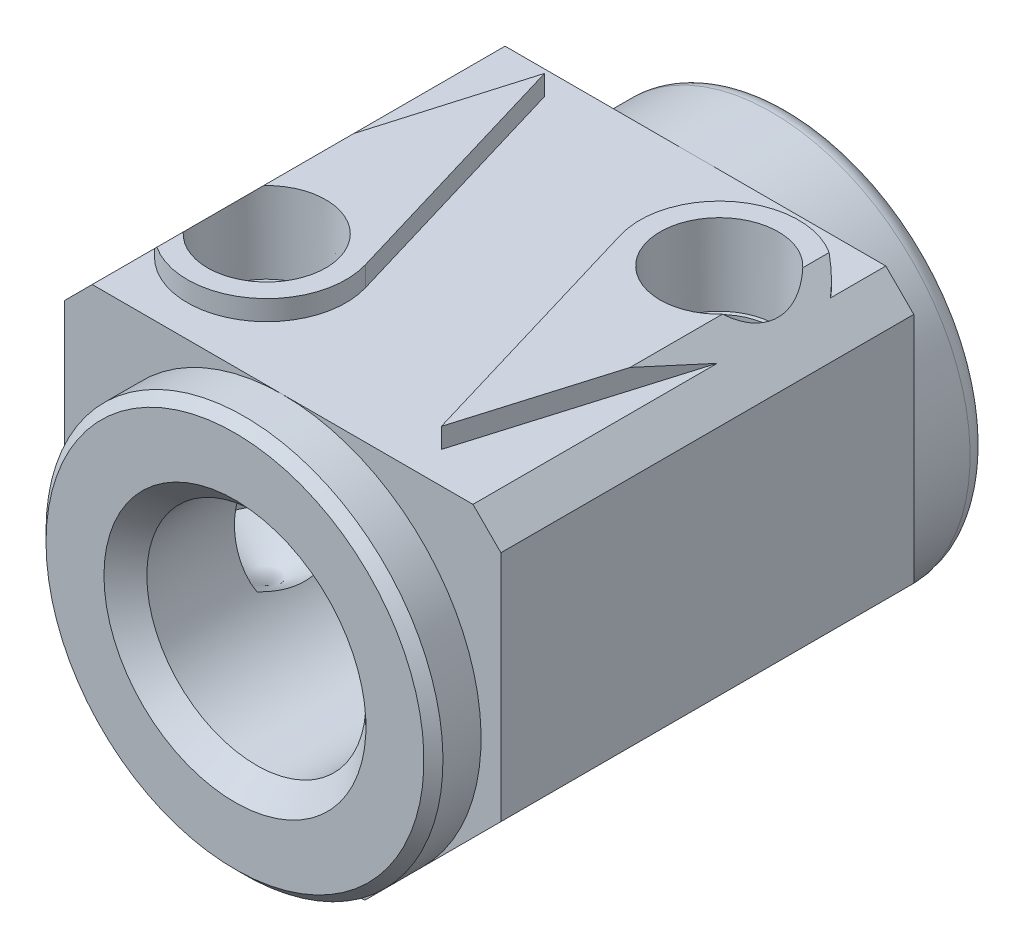
from build123d import *

# Parameters (mm, degrees)
SKETCH1_W                         = 34.925
SKETCH1_H                         = 33.3502
EXTRUDE1_DEPTH                    = 44.45
CUT_EXTRUDE1_DEPTH                = 44.45
SKETCH3_OUTSIDE_W                 = 50.051
SKETCH3_OUTSIDE_H                 = 48.476
SKETCH3_OUTSIDE_R                 = 15.875
CUT_EXTRUDE2_DEPTH                = 3.81
F_1_8_NPT_TAPPED_HOLE1_AT_2_COUNT = 2
F_1_8_NPT_TAPPED_HOLE1_AT_2_PITCH = 25.78600444
SKETCH5_OUTSIDE_W                 = 50.051
SKETCH5_OUTSIDE_H                 = 48.476
SKETCH5_OUTSIDE_R                 = 15.875
CUT_EXTRUDE3_DEPTH                = 7.62
SKETCH6_W                         = 34.925
SKETCH6_H                         = 33.02
CUT_EXTRUDE4_DEPTH                = 1.6002
CUT_EXTRUDE5_DEPTH                = 45.45
F_5_8_0_625_DIAMETER_HOLE1_D      = 15.875
F_3_4_16_TAPPED_HOLE1_D           = 17.526
F_3_4_16_TAPPED_HOLE1_DEPTH       = 25.4
F_3_4_16_TAPPED_HOLE1_TIP         = 5.265341605
SKETCH16_R                        = 10.16
CUT_EXTRUDE7_DEPTH                = 3.556
CHAMFER1_SIZE                     = 0.762
FILLET1_R                         = 1.524
CHAMFER2_SIZE                     = 1.7145
SKETCH18_R                        = 8.763
CUT_EXTRUDE9_DEPTH                = 7.62


with BuildPart() as part:
    # Sketch1 → Extrude1 (new body)
    with BuildSketch(Plane.XY):
        with Locations((17.4625, 16.6751)):
            Rectangle(SKETCH1_W, SKETCH1_H)
    extrude(amount=EXTRUDE1_DEPTH)

    # Sketch2 → Cut-Extrude1 (cut)
    with BuildSketch(Plane.XY.offset(44.45)):
        Polygon((24.038140303, 0), (34.925, 10.886859697), (38.95323648, 7.676224118), (37.650767603, -4.874839611), (-1.660111248, -5.999699096), (-2.784970733, 8.327458557), (0, 10.886859697), (10.886859697, 0), (18.528156354, -3.690776995), align=None)
    extrude(amount=-CUT_EXTRUDE1_DEPTH, mode=Mode.SUBTRACT)

    # Sketch3 outside → Cut-Extrude2 (cut)
    with BuildSketch(Plane.XY.offset(44.45)):
        with Locations((17.4625, 16.675)):
            Rectangle(SKETCH3_OUTSIDE_W, SKETCH3_OUTSIDE_H)
        with Locations((17.4625, 15.875)):
            Circle(SKETCH3_OUTSIDE_R, mode=Mode.SUBTRACT)
    extrude(amount=-CUT_EXTRUDE2_DEPTH, mode=Mode.SUBTRACT)

    # Sketch4 → 1/8 NPT Tapped Hole1 (revolve, cut)
    with BuildSketch(Plane(origin=(7.3025, 33.3502, 31.75), x_dir=(0, 0, 1), z_dir=(1, 0, 0))):
        Polygon((0, 0), (0, 24.377468714), (4.2164, 21.844), (4.2164, 6.35), (4.537409396, 6.35), (4.7275369, 0), align=None)
    f_1_8_npt_tapped_hole1 = revolve(axis=Axis((7.3025, 39.7002, 31.75), (0, -1, 0)), mode=Mode.SUBTRACT)

    # 1/8 NPT Tapped Hole1 at 2: 1/8 NPT Tapped Hole1 ×2
    with Locations(*[Vector(0.788024374, 0, -0.615644042) * (i * F_1_8_NPT_TAPPED_HOLE1_AT_2_PITCH) for i in range(1, F_1_8_NPT_TAPPED_HOLE1_AT_2_COUNT)]):
        add(f_1_8_npt_tapped_hole1, mode=Mode.SUBTRACT)

    # Sketch5 outside → Cut-Extrude3 (cut)
    with BuildSketch(Plane(origin=(0, 0, 0), x_dir=(-1, 0, 0), z_dir=(0, 0, -1))):
        with Locations((-17.4625, 16.675)):
            Rectangle(SKETCH5_OUTSIDE_W, SKETCH5_OUTSIDE_H)
        with Locations(Location((-17.4625, 15.875, 0), (0, 0, 180))):  # turned: the seam where the file's is
            Circle(SKETCH5_OUTSIDE_R, mode=Mode.SUBTRACT)
    extrude(amount=-CUT_EXTRUDE3_DEPTH, mode=Mode.SUBTRACT)

    # Sketch6 → Cut-Extrude4 (cut)
    with BuildSketch(Plane(origin=(0, 33.3502, 0), x_dir=(-1, 0, 0), z_dir=(0, 1, 0))):
        with Locations((-17.4625, 24.13)):
            Rectangle(SKETCH6_W, SKETCH6_H)
        with BuildLine():
            Line((-33.707799282, 17.689285714), (-27.6225, 38.1))
            Line((-27.6225, 38.1), (-21.537200718, 17.689285714))
            ThreePointArc((-21.537200718, 17.689285714), (-27.6225, 9.525), (-33.707799282, 17.689285714))
        make_face(mode=Mode.SUBTRACT)
        with BuildLine():
            Line((-7.3025, 9.525), (-13.387799282, 29.935714286))
            ThreePointArc((-13.387799282, 29.935714286), (-7.839432762, 38.077258744), (-0.998497845, 30.98707351))
            ThreePointArc((-0.998497845, 30.98707351), (-1.209886072, 29.96043147), (-1.587281519, 28.982550324))
            Line((-1.587281519, 28.982550324), (-7.3025, 9.525))
        make_face(mode=Mode.SUBTRACT)
    extrude(amount=-CUT_EXTRUDE4_DEPTH, mode=Mode.SUBTRACT)

    # Sketch8 → Cut-Extrude5 (cut, through all)
    with BuildSketch(Plane.XY.offset(44.45)):
        Polygon((0, 29.5148), (8.827956785, 38.342756785), (29.988545511, 34.451254489), (34.925, 29.5148), (37.769173864, 38.094844764), (-2.725767603, 41.455222953), (-4.620267788, 29.436987401), align=None)
    extrude(amount=-CUT_EXTRUDE5_DEPTH, mode=Mode.SUBTRACT)

    # 5/8 (0.625) Diameter Hole1 (through all)
    with Locations(Plane(origin=(17.4625, 15.875, 44.45), x_dir=(1, 0, 0), z_dir=(0, 0, 1))):
        with Locations((0, 0)):
            Hole(F_5_8_0_625_DIAMETER_HOLE1_D / 2)

    # 3/4-16 Tapped Hole1
    with Locations(Plane(origin=(17.4625, 15.875, 44.45), x_dir=(1, 0, 0), z_dir=(0, 0, 1))):
        with Locations((0, 0)):
            Hole(F_3_4_16_TAPPED_HOLE1_D / 2, depth=F_3_4_16_TAPPED_HOLE1_DEPTH)
            with Locations((0, 0, -(F_3_4_16_TAPPED_HOLE1_DEPTH + F_3_4_16_TAPPED_HOLE1_TIP / 2))):  # 118° drill point
                Cone(0, F_3_4_16_TAPPED_HOLE1_D / 2, F_3_4_16_TAPPED_HOLE1_TIP, mode=Mode.SUBTRACT)

    # Sketch16 → Cut-Extrude7 (cut)
    with BuildSketch(Plane(origin=(0, 0, 5.715), x_dir=(-1, 0, 0), z_dir=(0, 0, -1))):
        with Locations((-17.4625, 15.875)):
            Circle(SKETCH16_R)
    extrude(amount=-CUT_EXTRUDE7_DEPTH, mode=Mode.SUBTRACT)

    # Chamfer1
    chamfer1_edges = [part.edges().sort_by_distance(p)[0] for p in [
        (25.4, 15.875, 0),
        (1.5875, 15.875, 44.45),
    ]]
    chamfer(chamfer1_edges, length=CHAMFER1_SIZE)

    # Fillet1
    fillet1_edges = [part.edges().sort_by_distance(p)[0] for p in [
        (1.5875, 15.875, 0),
    ]]
    fillet(fillet1_edges, radius=FILLET1_R)

    # Chamfer2
    chamfer2_edges = [part.edges().sort_by_distance(p)[0] for p in [
        (26.2255, 15.875, 44.45),
    ]]
    chamfer(chamfer2_edges, length=CHAMFER2_SIZE)

    # Sketch18 → Cut-Extrude9 (cut)
    with BuildSketch(Plane(origin=(0, 0, 12.446), x_dir=(-1, 0, 0), z_dir=(0, 0, -1))):
        with Locations(Location((-17.4625, 15.875, 0), (0, 0, 208.426476552))):  # turned: the seam where the file's is
            Circle(SKETCH18_R)
    extrude(amount=-CUT_EXTRUDE9_DEPTH, mode=Mode.SUBTRACT)


solid = part.part
